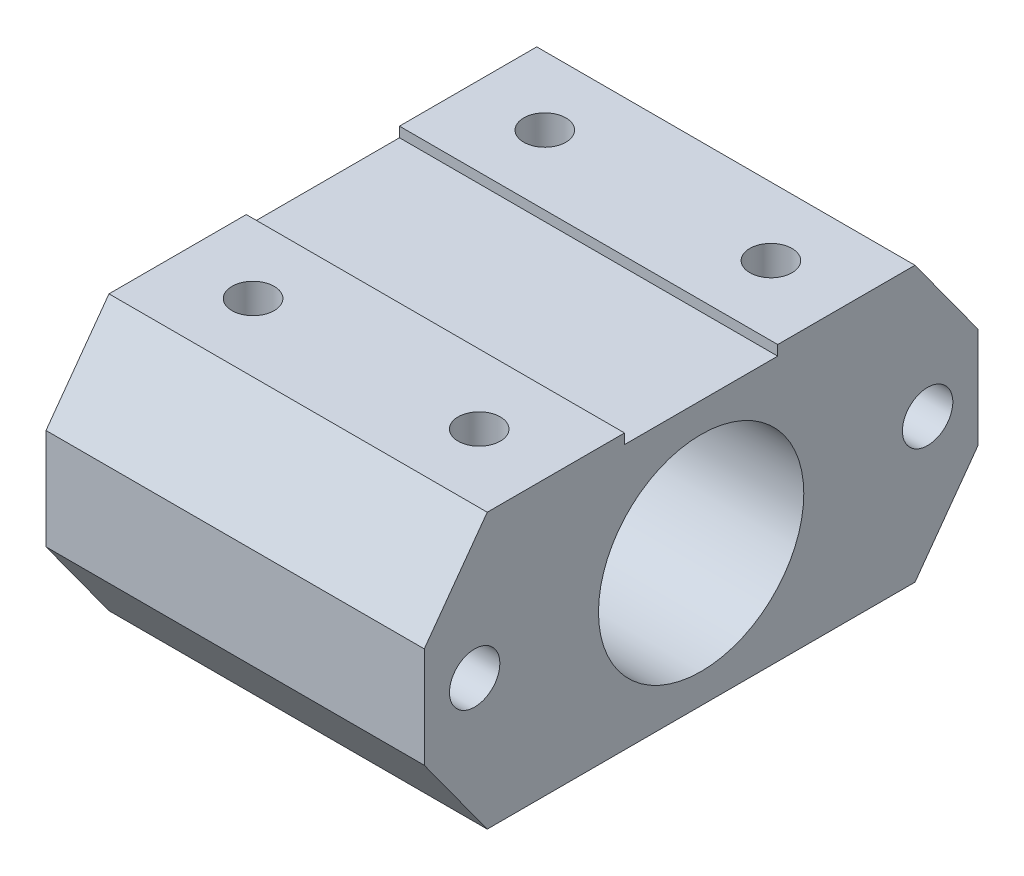
from build123d import *

# Parameters (mm, degrees)
SKETCH1_W           = 30.03
SKETCH1_H           = 33.96
SKETCH1_R           = 1.675
BOSS_EXTRUDE4_DEPTH = 21.79
SKETCH5_R           = 8.15
CUT_EXTRUDE1_DEPTH  = 31.03
SKETCH7_W           = 30.03
SKETCH7_H           = 12.16
CUT_EXTRUDE2_DEPTH  = 0.8
SKETCH10_R          = 8.15
SKETCH10_R_2        = 4.75
BOSS_EXTRUDE6_DEPTH = 3
BOSS_EXTRUDE7_DEPTH = 30.03
SKETCH13_R          = 2
CUT_EXTRUDE4_DEPTH  = 10


with BuildPart() as part:
    # Sketch1 → Boss-Extrude4 (new body)
    with BuildSketch(Plane(origin=(0, 0, 0), x_dir=(1, 0, 0), z_dir=(0, 1, 0))):
        with Locations((15.015, 16.98)):
            Rectangle(SKETCH1_W, SKETCH1_H)
        with Locations((23.99, 28.56)):
            Circle(SKETCH1_R, mode=Mode.SUBTRACT)
        with Locations((6.04, 28.56)):
            Circle(SKETCH1_R, mode=Mode.SUBTRACT)
        with Locations((23.99, 5.4)):
            Circle(SKETCH1_R, mode=Mode.SUBTRACT)
        with Locations((6.04, 5.4)):
            Circle(SKETCH1_R, mode=Mode.SUBTRACT)
    extrude(amount=BOSS_EXTRUDE4_DEPTH)

    # Sketch5 → Cut-Extrude1 (cut, through all)
    with BuildSketch(Plane(origin=(30.03, 0, 0), x_dir=(0, 0, -1), z_dir=(1, 0, 0))):
        with Locations((16.98, 10.5)):
            Circle(SKETCH5_R)
    extrude(amount=-CUT_EXTRUDE1_DEPTH, mode=Mode.SUBTRACT)

    # Sketch7 → Cut-Extrude2 (cut)
    with BuildSketch(Plane(origin=(0, 21.79, 0), x_dir=(1, 0, 0), z_dir=(0, 1, 0))):
        with Locations((15.015, 16.98)):
            Rectangle(SKETCH7_W, SKETCH7_H)
    extrude(amount=-CUT_EXTRUDE2_DEPTH, mode=Mode.SUBTRACT)

    # Sketch10 → Boss-Extrude6 (add)
    with BuildSketch(Plane.ZY):
        with Locations((-16.98, 10.5)):
            Circle(SKETCH10_R)
        with Locations((-16.98, 10.5)):
            Circle(SKETCH10_R_2, mode=Mode.SUBTRACT)
    extrude(amount=-BOSS_EXTRUDE6_DEPTH)

    # Sketch12 → Boss-Extrude7 (add)
    with BuildSketch(Plane.ZY):
        Polygon((5, 14.895), (0, 21.79), (0, 14.895), (0, 6.895), (0, 0), (5, 6.895), align=None)
        Polygon((-33.96, 14.895), (-33.96, 6.895), (-33.96, 0), (-38.96, 6.895), (-38.96, 14.895), (-33.96, 21.79), align=None)
    extrude(amount=-BOSS_EXTRUDE7_DEPTH)

    # Sketch13 → Cut-Extrude4 (cut)
    with BuildSketch(Plane(origin=(30.03, 0, 0), x_dir=(0, 0, -1), z_dir=(1, 0, 0))):
        with Locations((-1, 10.895)):
            Circle(SKETCH13_R)
        with Locations((34.96, 10.895)):
            Circle(SKETCH13_R)
    extrude(amount=-CUT_EXTRUDE4_DEPTH, mode=Mode.SUBTRACT)


solid = part.part
